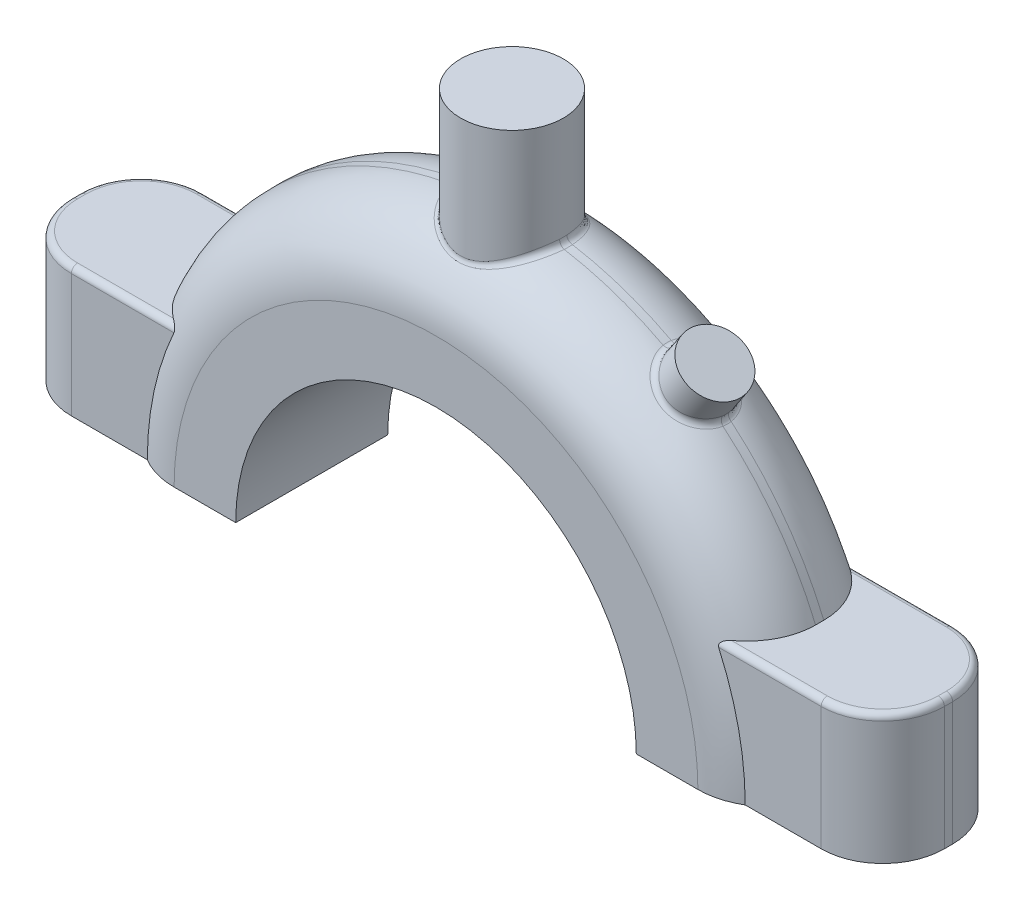
from build123d import *

# Parameters (mm, degrees)
BOSS_EXTRUDE2_DEPTH = 18.796
FILLET1_R           = 17.78
SKETCH9_W           = 50.8
SKETCH9_H           = 32.512
BOSS_EXTRUDE3_DEPTH = 32.004
FILLET2_R           = 15.24
SKETCH11_R          = 7.62
BOSS_EXTRUDE4_DEPTH = 32.004
SKETCH12_R          = 12.7
BOSS_EXTRUDE5_DEPTH = 32.004
FILLET3_R           = 1.524


with BuildPart() as part:
    # Sketch8 → Boss-Extrude2 (new body, symmetric)
    with BuildSketch(Plane.XY):
        with BuildLine():
            Line((-49.53, 0), (-82.55, 0))
            ThreePointArc((-82.55, 0), (0, 82.55), (82.55, 0))
            Line((82.55, 0), (49.53, 0))
            ThreePointArc((49.53, 0), (0, 49.53), (-49.53, 0))
        make_face()
    extrude(amount=BOSS_EXTRUDE2_DEPTH, both=True)

    # Fillet1
    fillet1_edges = [part.edges().sort_by_distance(p)[0] for p in [
        (0, 82.55, 18.796),
        (0, 82.55, -18.796),
    ]]
    fillet(fillet1_edges, radius=FILLET1_R)

    # Sketch9 → Boss-Extrude3 (add)
    with BuildSketch(Plane.XZ):
        with Locations((-82.55, 0)):
            Rectangle(SKETCH9_W, SKETCH9_H)
        with Locations((82.55, 0)):
            Rectangle(SKETCH9_W, SKETCH9_H)
    extrude(amount=-BOSS_EXTRUDE3_DEPTH)

    # Fillet2
    fillet2_edges = [part.edges().sort_by_distance(p)[0] for p in [
        (107.95, 16.002, 16.256),
        (107.95, 16.002, -16.256),
        (-107.95, 16.002, -16.256),
        (-107.95, 16.002, 16.256),
    ]]
    fillet(fillet2_edges, radius=FILLET2_R)

    # Sketch11 → Boss-Extrude4 (add)
    with BuildSketch(Plane(origin=(50.176257431, 74.613874355, 0), x_dir=(-0.829817545, 0.558034804, 0), z_dir=(-0.558034804, -0.829817545, 0))):
        Circle(SKETCH11_R)
    extrude(amount=BOSS_EXTRUDE4_DEPTH)

    # Sketch12 → Boss-Extrude5 (add)
    with BuildSketch(Plane(origin=(0, 108.356349619, 0), x_dir=(1, 0, 0), z_dir=(0, 1, 0))):
        Circle(SKETCH12_R)
    extrude(amount=-BOSS_EXTRUDE5_DEPTH)

    # Fillet3
    fillet3_edges = [part.edges().sort_by_distance(p)[0] for p in [
        (-79.675819277, 32.004, -16.256),
        (-103.486307345, 32.004, -11.792307345),
        (-107.95, 32.004, 0),
        (-103.486307345, 32.004, 11.792307345),
        (79.675819277, 32.004, -16.256),
        (103.486307345, 32.004, -11.792307345),
        (107.95, 32.004, 0),
        (103.486307345, 32.004, 11.792307345),
        (52.192306356, 63.956748332, 0),
        (52.192306356, 63.956748332, 0),
        (45.355978485, 67.445948606, -7.619999999),
        (12.7, 94.961788247, 0),
        (-12.7, 81.567226875, 0),
        (0, 78.171960454, -12.7),
        (-79.675819277, 32.004, 16.256),
        (79.675819277, 32.004, 16.256),
        (45.355978485, 67.445948606, 7.619999999),
        (0, 78.171960454, 12.7),
    ]]
    fillet(fillet3_edges, radius=FILLET3_R)


solid = part.part
